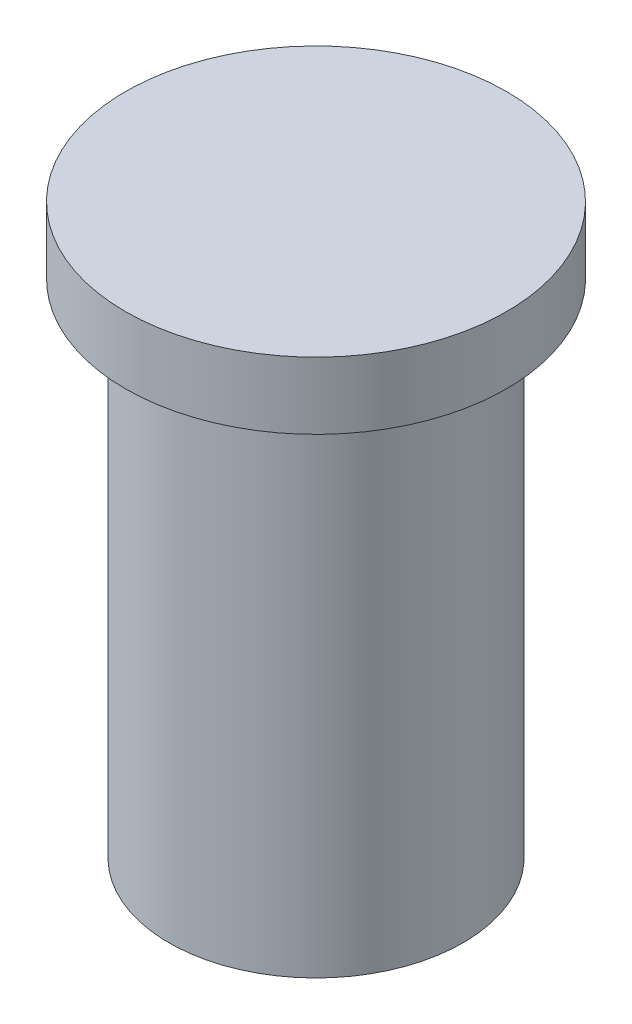
from build123d import *


with BuildPart() as part:
    # Sketch1 → Revolve1 (revolve)
    with BuildSketch(Plane.XY, mode=Mode.PRIVATE) as revolve1_sk:
        Polygon((0, 0), (22, 0), (22, 75), (28.5, 75), (28.5, 85), (0, 85), align=None)
    revolve(revolve1_sk.sketch.rotate(Axis((0, 0, 0), (0, 1, 0)), 90), axis=Axis((0, 0, 0), (0, 1, 0)))  # turned: the seam where the file's is


solid = part.part
